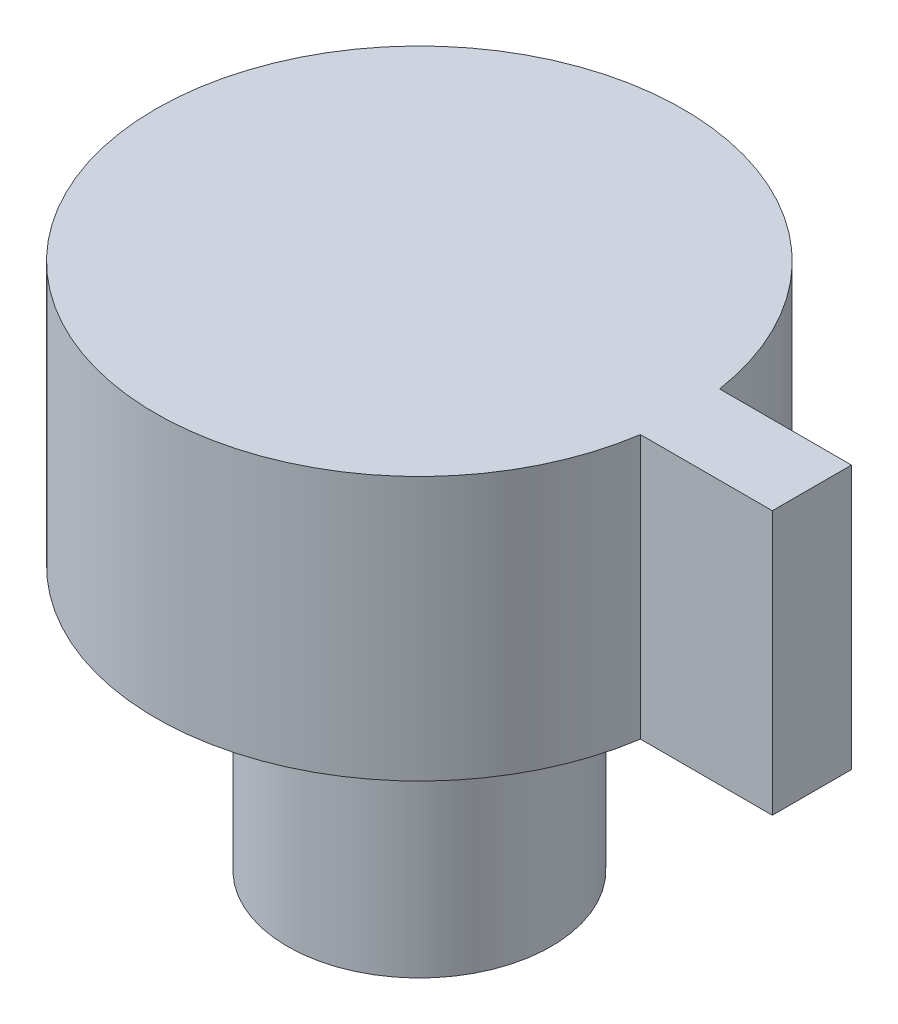
from build123d import *

# Parameters (mm, degrees)
BOSS_EXTRUDE1_DEPTH = 10
SKETCH1_3_R         = 5
BOSS_EXTRUDE2_DEPTH = 10


with BuildPart() as part:
    # Sketch1 → Boss-Extrude1 (new body)
    with BuildSketch(Plane(origin=(0, 0, 0), x_dir=(1, 0, 0), z_dir=(0, 1, 0))):
        with BuildLine():
            Line((-51.169981336, -16.214278262), (-56.169981336, -16.214278262))
            ThreePointArc((-56.169981336, -16.214278262), (-76.049815498, -17.714278262), (-56.169981336, -19.214278262))
            Line((-56.169981336, -19.214278262), (-51.169981336, -19.214278262))
            Line((-51.169981336, -19.214278262), (-51.169981336, -16.214278262))
        make_face()
    extrude(amount=BOSS_EXTRUDE1_DEPTH)

    # Sketch1_3 → Boss-Extrude2 (add)
    with BuildSketch(Plane(origin=(0, 0, 0), x_dir=(1, 0, 0), z_dir=(0, 1, 0))):
        with Locations((-66.053308407, -17.714278262)):
            Circle(SKETCH1_3_R)
    extrude(amount=-BOSS_EXTRUDE2_DEPTH)


solid = part.part
